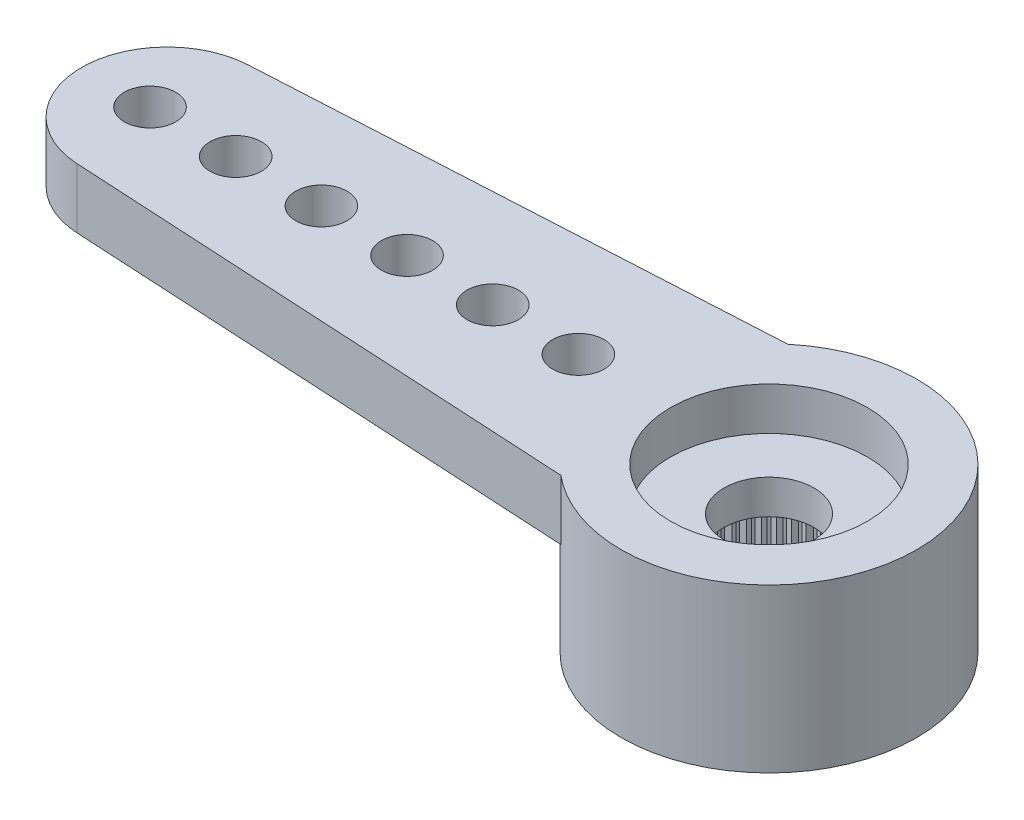
from build123d import *

# Parameters (mm, degrees)
RESSALTO_EXTRUS_O1_DEPTH = 1.4
ESBO_O2_R                = 3.45
RESSALTO_EXTRUS_O2_DEPTH = 2.4
FURO4_D                  = 1.2
PADR_O_LINEAR1_COUNT     = 6
PADR_O_LINEAR1_PITCH     = 2
FURO1_D                  = 4.95
FURO1_DEPTH              = 2
FURO2_D                  = 4.6
FURO2_DEPTH              = 1
FURO3_D                  = 2.1
RESSALTO_EXTRUS_O3_DEPTH = 2
PADR_OCIRCULAR1_COUNT    = 60


with BuildPart() as part:
    # Esboço1 → Ressalto-extrusão1 (new body)
    with BuildSketch(Plane(origin=(0, 0, 0), x_dir=(1, 0, 0), z_dir=(0, 1, 0))):
        with BuildLine():
            Line((-14.159121967, 1.99702088), (-2.209072203, 2.65))
            ThreePointArc((-2.209072203, 2.65), (3.45, 0), (-2.209072203, -2.65))
            Line((-2.209072203, -2.65), (-14.159121967, -1.99702088))
            ThreePointArc((-14.159121967, -1.99702088), (-16.05, 0), (-14.159121967, 1.99702088))
        make_face()
    extrude(amount=-RESSALTO_EXTRUS_O1_DEPTH)

    # Esboço2 → Ressalto-extrusão2 (add)
    with BuildSketch(Plane.XZ.offset(1.4)):
        Circle(ESBO_O2_R)
    extrude(amount=RESSALTO_EXTRUS_O2_DEPTH)

    # Furo4 (through all)
    with Locations(Plane(origin=(0, 0, 0), x_dir=(1, 0, 0), z_dir=(0, 1, 0))):
        with Locations((-14.45, 0)):
            furo4 = Hole(FURO4_D / 2)

    # Padrão linear1: Furo4 ×6
    with Locations(*[(i * PADR_O_LINEAR1_PITCH, 0, 0) for i in range(1, PADR_O_LINEAR1_COUNT)]):
        add(furo4, mode=Mode.SUBTRACT)

    # Furo1
    with Locations(Plane(origin=(0, -3.8, 0), x_dir=(-1, 0, 0), z_dir=(0, -1, 0))):
        with Locations((0, 0)):
            Hole(FURO1_D / 2, depth=FURO1_DEPTH)

    # Furo2
    with Locations(Plane(origin=(0, 0, 0), x_dir=(1, 0, 0), z_dir=(0, 1, 0))):
        with Locations((0, 0)):
            Hole(FURO2_D / 2, depth=FURO2_DEPTH)

    # Furo3 (through all)
    with Locations(Plane(origin=(0, 0, 0), x_dir=(1, 0, 0), z_dir=(0, 1, 0))):
        with Locations((0, 0)):
            Hole(FURO3_D / 2)

    # Esboço11 → Ressalto-extrusão3 (add)
    with BuildSketch(Plane.XZ.offset(3.8)):
        with BuildLine():
            ThreePointArc((0.098056786, 2.473056786), (0, 2.475), (-0.098056786, 2.473056786))
            Line((-0.098056786, 2.473056786), (0, 2.375))
            Line((0, 2.375), (0.098056786, 2.473056786))
        make_face()
    ressalto_extrus_o3 = extrude(amount=-RESSALTO_EXTRUS_O3_DEPTH)

    # PadrãoCircular1: Ressalto-extrusão3 ×60 about axis
    padr_ocircular1_axis = Axis((0, 0, 0), (0, 1, 0))
    for i in range(1, PADR_OCIRCULAR1_COUNT):
        add(ressalto_extrus_o3.rotate(padr_ocircular1_axis, i * 360 / PADR_OCIRCULAR1_COUNT))


solid = part.part
